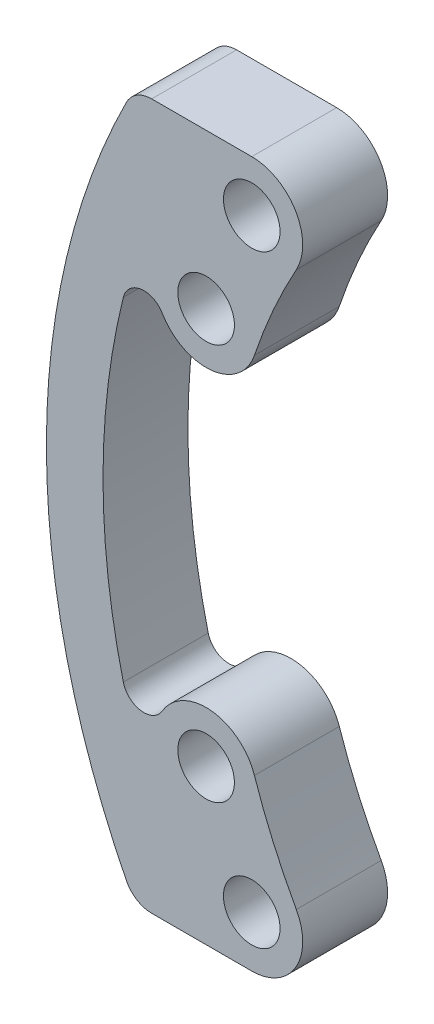
from build123d import *

# Parameters (mm, degrees)
SKETCH_1_R        = 1
EXTRUDE_1_DEPTH   = 1.5
EXTRUDE_1_2_DEPTH = 1.5
EXTRUDE_2_DEPTH   = 3
FILLET_1_R        = 1


with BuildPart() as part:
    # 草图1 → 凸台-拉伸1 (new body, symmetric)
    with BuildSketch(Plane.XY):
        with BuildLine():
            ThreePointArc((-20.819004975, 11.532954168), (-21.781247924, 9.592561643), (-22.563107092, 7.572727273))
            ThreePointArc((-22.563107092, 7.572727273), (-21.429380887, 5.293546522), (-19.150200137, 6.427272727))
            ThreePointArc((-19.150200137, 6.427272727), (-18.486605381, 8.141585932), (-17.669911786, 9.788473706))
            ThreePointArc((-17.669911786, 9.788473706), (-18.372218149, 12.235260532), (-20.819004975, 11.532954168))
        make_face()
        with Locations((-19.24445838, 10.660713937)):
            Circle(SKETCH_1_R, mode=Mode.SUBTRACT)
        with Locations((-20.856653615, 7)):
            Circle(SKETCH_1_R, mode=Mode.SUBTRACT)
    extrude(amount=EXTRUDE_1_DEPTH, both=True)



with BuildPart() as body_2:
    # 草图1 → Extrude 1 2 (new body, symmetric)
    with BuildSketch(Plane.XY):
        with BuildLine():
            ThreePointArc((-20.819004975, -11.532954168), (-21.781247924, -9.592561643), (-22.563107092, -7.572727273))
            ThreePointArc((-22.563107092, -7.572727273), (-21.429380887, -5.293546522), (-19.150200137, -6.427272727))
            ThreePointArc((-19.150200137, -6.427272727), (-18.486605381, -8.141585932), (-17.669911786, -9.788473706))
            ThreePointArc((-17.669911786, -9.788473706), (-18.372218149, -12.235260532), (-20.819004975, -11.532954168))
        make_face()
        with Locations((-19.24445838, -10.660713937)):
            Circle(SKETCH_1_R, mode=Mode.SUBTRACT)
        with Locations((-20.856653615, -7)):
            Circle(SKETCH_1_R, mode=Mode.SUBTRACT)
    extrude(amount=EXTRUDE_1_2_DEPTH, both=True)


with BuildPart() as part_1:
    add(part.part)

    add(body_2.part)  # 凸台-拉伸2 merges body 2
    # 草图2 → 凸台-拉伸2 (add)
    with BuildSketch(Plane.XY.offset(1.5)):
        with BuildLine():
            Line((-19.24445838, 12.460713937), (-23.387616556, 12.460713937))
            ThreePointArc((-23.387616556, 12.460713937), (-26.5, 0), (-23.387616556, -12.460713937))
            Line((-23.387616556, -12.460713937), (-19.24445838, -12.460713937))
            ThreePointArc((-19.24445838, -12.460713937), (-20.158232856, -12.211525404), (-20.819004975, -11.532954168))
            ThreePointArc((-20.819004975, -11.532954168), (-21.781247924, -9.592561643), (-22.563107092, -7.572727273))
            ThreePointArc((-22.563107092, -7.572727273), (-22.646911391, -6.812978362), (-22.407893773, -6.086953468))
            ThreePointArc((-22.407893773, -6.086953468), (-23.162368256, -6.448682563), (-23.782272592, -5.886723226))
            ThreePointArc((-23.782272592, -5.886723226), (-24.5, 0), (-23.782272592, 5.886723226))
            ThreePointArc((-23.782272592, 5.886723226), (-23.162368256, 6.448682563), (-22.407893773, 6.086953468))
            ThreePointArc((-22.407893773, 6.086953468), (-22.646911391, 6.812978362), (-22.563107092, 7.572727273))
            ThreePointArc((-22.563107092, 7.572727273), (-21.781247924, 9.592561643), (-20.819004975, 11.532954168))
            ThreePointArc((-20.819004975, 11.532954168), (-20.158232856, 12.211525404), (-19.24445838, 12.460713937))
        make_face()
    extrude(amount=-EXTRUDE_2_DEPTH)

    # 圆角1
    fillet_1_edges = [part_1.edges().sort_by_distance(p)[0] for p in [
        (-23.387616556, -12.460713937, 0),
        (-23.387616556, 12.460713937, 0),
    ]]
    fillet(fillet_1_edges, radius=FILLET_1_R)


solid = part_1.part
